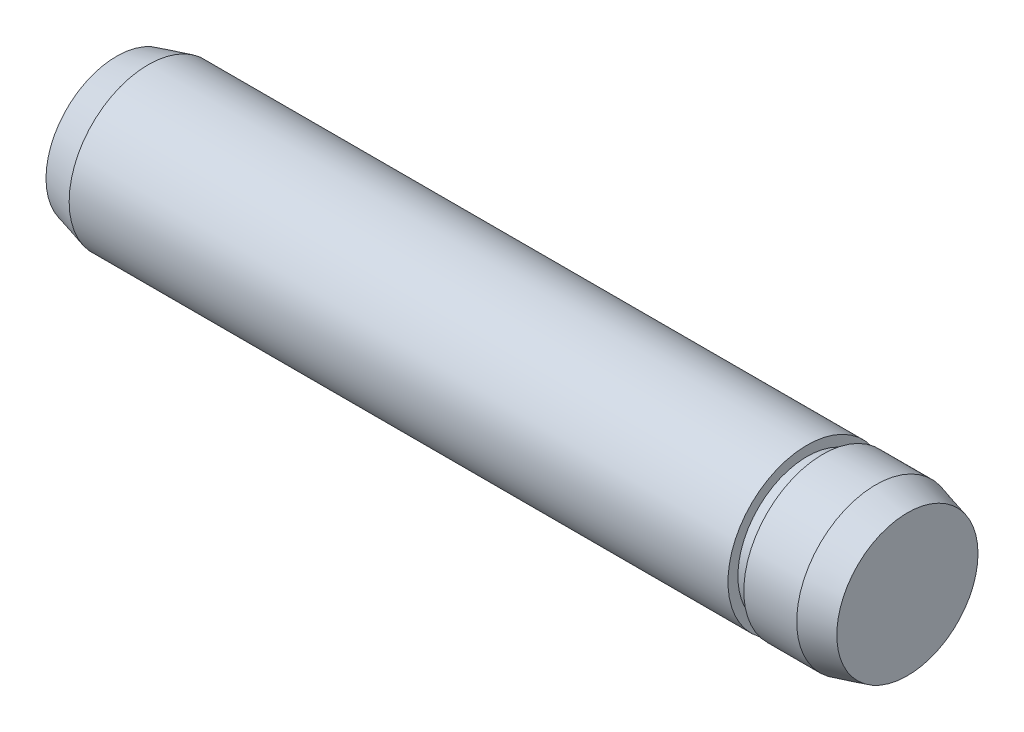
from build123d import *

# Parameters (mm, degrees)
SKETCH2_R           = 4
EXTRUDE1_DEPTH      = 18.4
EXTRUDE1_DEPTH_BACK = 18.4
SKETCH3_R           = 4
EXTRUDE2_DEPTH      = 1.6
EXTRUDE2_TAPER      = 15
SKETCH4_R           = 4
EXTRUDE3_DEPTH      = 1.6
EXTRUDE3_TAPER      = 15
SKETCH5_R           = 4
SKETCH5_R_2         = 3.5
CUT_EXTRUDE1_DEPTH  = 0.8


with BuildPart() as part:
    # Sketch2 → Extrude1 (new body, two sides)
    with BuildSketch(Plane(origin=(0, 0, 0), x_dir=(0, 0, -1), z_dir=(1, 0, 0))) as extrude1_sk:
        Circle(SKETCH2_R)
    extrude(amount=EXTRUDE1_DEPTH)
    extrude(extrude1_sk.sketch, amount=-EXTRUDE1_DEPTH_BACK)

    # Sketch3 → Extrude2 (add)
    with BuildSketch(Plane(origin=(18.4, 0, 0), x_dir=(0, 0, -1), z_dir=(1, 0, 0))):
        Circle(SKETCH3_R)
    extrude(amount=EXTRUDE2_DEPTH, taper=EXTRUDE2_TAPER)

    # Sketch4 → Extrude3 (add)
    with BuildSketch(Plane.ZY.offset(18.4)):
        Circle(SKETCH4_R)
    extrude(amount=EXTRUDE3_DEPTH, taper=EXTRUDE3_TAPER)

    # Sketch5 → Cut-Extrude1 (cut)
    with BuildSketch(Plane(origin=(14.92499999, 0, 0), x_dir=(0, 0, -1), z_dir=(1, 0, 0))):
        Circle(SKETCH5_R)
        Circle(SKETCH5_R_2, mode=Mode.SUBTRACT)
    extrude(amount=CUT_EXTRUDE1_DEPTH, mode=Mode.SUBTRACT)


solid = part.part
